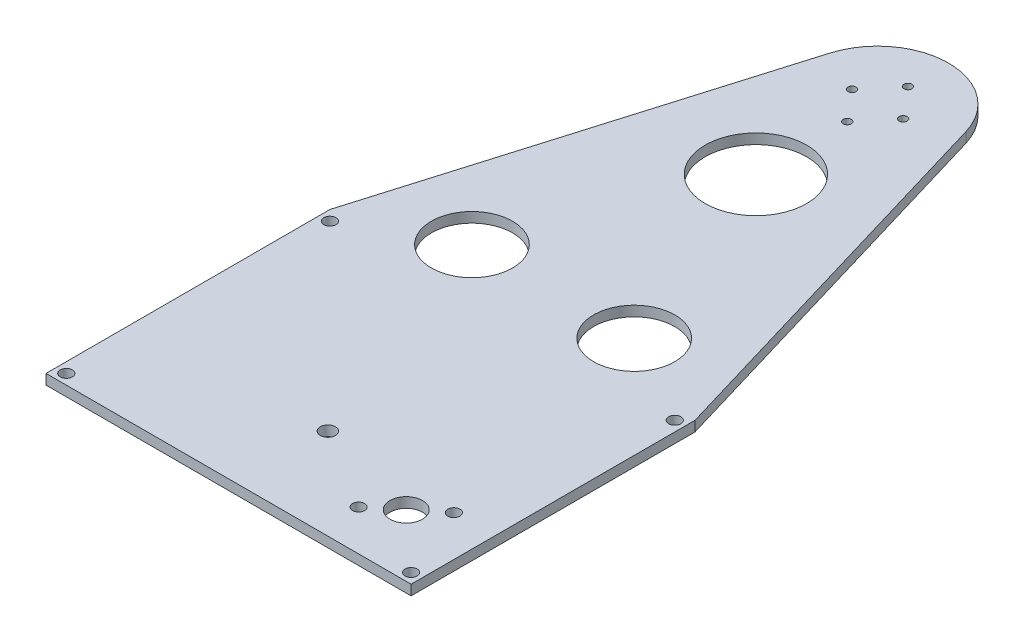
from build123d import *

# Parameters (mm, degrees)
SKETCH3_W                = 114.3
SKETCH3_H                = 88.9
SKETCH3_W_2              = 101.6
SKETCH3_H_2              = 76.2
BOSS_EXTRUDE1_DEPTH      = 12.7
BOSS_EXTRUDE1_DEPTH_BACK = 12.7
SKETCH4_W                = 114.3
SKETCH4_H                = 88.9
BOSS_EXTRUDE2_DEPTH      = 3.175
BOSS_EXTRUDE3_DEPTH      = 3.175
SKETCH7_W                = 44.45
SKETCH7_H                = 25.4
BOSS_EXTRUDE4_DEPTH      = 6.35
SKETCH6_R                = 9.9695
CUT_EXTRUDE1_DEPTH       = 115.3
SKETCH13_W               = 29.21
SKETCH13_H               = 25.4
BOSS_EXTRUDE5_DEPTH      = 4.064
SKETCH14_W               = 6.35
SKETCH14_H               = 2.54
CUT_EXTRUDE2_DEPTH       = 31.75
SKETCH18_W               = 10.16
SKETCH18_H               = 5.08
CUT_EXTRUDE3_DEPTH       = 6.35
SKETCH19_R               = 0.635
CUT_EXTRUDE4_DEPTH       = 25.4
SKETCH20_R               = 1.905
CUT_EXTRUDE7_DEPTH       = 3.175
SKETCH23_R               = 5.08
SKETCH23_R_2             = 1.905
SKETCH23_R_3             = 2.38125
CUT_EXTRUDE8_DEPTH       = 3.175
SKETCH24_R               = 1.25
CUT_EXTRUDE9_DEPTH       = 3.175
BOSS_EXTRUDE7_DEPTH      = 114.3
BOSS_EXTRUDE8_DEPTH      = 28.575
SKETCH25_R               = 15.875
SKETCH25_R_2             = 12.7
CUT_EXTRUDE10_DEPTH      = 32.75
FILLET1_R                = 9.525
FILLET2_R                = 5.08
FILLET3_R                = 9.525


with BuildPart() as part:
    # Sketch3 → Boss-Extrude1 (new body, two sides)
    with BuildSketch(Plane(origin=(0, 0, 0), x_dir=(1, 0, 0), z_dir=(0, 1, 0))) as boss_extrude1_sk:
        with Locations((0, -158.75)):
            Rectangle(SKETCH3_W, SKETCH3_H)
        with Locations((0, -158.75)):
            Rectangle(SKETCH3_W_2, SKETCH3_H_2, mode=Mode.SUBTRACT)
    extrude(amount=BOSS_EXTRUDE1_DEPTH)
    extrude(boss_extrude1_sk.sketch, amount=-BOSS_EXTRUDE1_DEPTH_BACK)

    # Sketch4 → Boss-Extrude2 (add)
    with BuildSketch(Plane.XZ.offset(12.7)):
        with Locations((0, 158.75)):
            Rectangle(SKETCH4_W, SKETCH4_H)
    extrude(amount=BOSS_EXTRUDE2_DEPTH)

    # Sketch7 → Boss-Extrude4 (add)
    with BuildSketch(Plane(origin=(0, -12.7, 0), x_dir=(1, 0, 0), z_dir=(0, 1, 0))):
        with Locations((-28.575, -133.35)):
            Rectangle(SKETCH7_W, SKETCH7_H)
        with Locations((28.575, -133.35)):
            Rectangle(SKETCH7_W, SKETCH7_H)
    extrude(amount=BOSS_EXTRUDE4_DEPTH)

    # Sketch6 → Cut-Extrude1 (cut, through all)
    with BuildSketch(Plane.ZY.offset(57.15)):
        with Locations((133.35, 0)):
            Circle(SKETCH6_R)
    extrude(amount=-CUT_EXTRUDE1_DEPTH, mode=Mode.SUBTRACT)

    # Sketch13 → Boss-Extrude5 (add)
    with BuildSketch(Plane(origin=(0, -12.7, 0), x_dir=(1, 0, 0), z_dir=(0, 1, 0))):
        with Locations((-20.955, -133.35)):
            Rectangle(SKETCH13_W, SKETCH13_H)
        with Locations((20.955, -133.35)):
            Rectangle(SKETCH13_W, SKETCH13_H)
    extrude(amount=BOSS_EXTRUDE5_DEPTH)

    # Sketch14 → Cut-Extrude2 (cut)
    with BuildSketch(Plane.XY.offset(146.05)):
        with Locations((-27.305, -10.414)):
            Rectangle(SKETCH14_W, SKETCH14_H)
        with Locations((-27.305, -3.81)):
            Rectangle(SKETCH14_W, SKETCH14_H)
        with Locations((27.305, -10.414)):
            Rectangle(SKETCH14_W, SKETCH14_H)
        with Locations((27.305, -3.81)):
            Rectangle(SKETCH14_W, SKETCH14_H)
    extrude(amount=-CUT_EXTRUDE2_DEPTH, mode=Mode.SUBTRACT)

    # Sketch18 → Cut-Extrude3 (cut)
    with BuildSketch(Plane.XY.offset(120.65)):
        with Locations((-43.18, 10.16)):
            Rectangle(SKETCH18_W, SKETCH18_H)
    extrude(amount=-CUT_EXTRUDE3_DEPTH, mode=Mode.SUBTRACT)

    # Sketch19 → Cut-Extrude4 (cut)
    with BuildSketch(Plane(origin=(0, 12.7, 0), x_dir=(1, 0, 0), z_dir=(0, 1, 0))):
        with Locations((-53.975, -117.475)):
            Circle(SKETCH19_R)
        with Locations((53.975, -117.475)):
            Circle(SKETCH19_R)
        with Locations((-53.975, -200.025)):
            Circle(SKETCH19_R)
        with Locations((53.975, -200.025)):
            Circle(SKETCH19_R)
    extrude(amount=-CUT_EXTRUDE4_DEPTH, mode=Mode.SUBTRACT)

    # Sketch26 → Boss-Extrude7 (add)
    with BuildSketch(Plane(origin=(57.15, 0, 0), x_dir=(0, 0, -1), z_dir=(1, 0, 0))):
        Polygon((-203.2, 12.7), (-203.454, 12.7), (-203.454, 15.875), (-204.724, 15.875), (-213.23138686, -15.875), (-203.2, -15.875), align=None)
    extrude(amount=-BOSS_EXTRUDE7_DEPTH)

    # Sketch27 → Boss-Extrude8 (add)
    with BuildSketch(Plane.XZ.offset(15.875)):
        Polygon((57.15, 171.45), (95.25, 171.45), (95.25, 128.27), (100.33, 128.27), (100.33, 176.536200973), (57.15, 184.15), align=None)
        Polygon((-100.33, 176.536200973), (-57.15, 184.15), (-57.15, 171.45), (-95.25, 171.45), (-95.25, 128.27), (-100.33, 128.27), align=None)
    extrude(amount=-BOSS_EXTRUDE8_DEPTH)

    # Fillet1
    fillet1_edges = [part.edges().sort_by_distance(p)[0] for p in [
        (57.15, -1.5875, 184.15),
        (100.33, -1.5875, 176.536200973),
        (95.25, -1.5875, 171.45),
        (-100.33, -1.5875, 176.536200973),
        (-57.15, -1.5875, 184.15),
        (-95.25, -1.5875, 171.45),
    ]]
    fillet(fillet1_edges, radius=FILLET1_R)

    # Fillet2
    fillet2_edges = [part.edges().sort_by_distance(p)[0] for p in [
        (57.15, -1.5875, 171.45),
        (-57.15, -1.5875, 171.45),
    ]]
    fillet(fillet2_edges, radius=FILLET2_R)

    # Fillet3
    fillet3_edges = [part.edges().sort_by_distance(p)[0] for p in [
        (97.79, -15.875, 128.27),
        (97.79, 12.7, 128.27),
        (-97.79, -15.875, 128.27),
        (-97.79, 12.7, 128.27),
    ]]
    fillet(fillet3_edges, radius=FILLET3_R)


with BuildPart() as body_2:
    # Sketch5 → Boss-Extrude3 (new body)
    with BuildSketch(Plane(origin=(0, 12.7, 0), x_dir=(1, 0, 0), z_dir=(0, 1, 0))):
        with BuildLine():
            Line((-21.304313257, 6.330628851), (-57.15, -114.3))
            Line((-57.15, -114.3), (-57.15, -203.2))
            Line((-57.15, -203.2), (57.15, -203.2))
            Line((57.15, -203.2), (57.15, -114.3))
            Line((57.15, -114.3), (21.304313257, 6.330628851))
            ThreePointArc((21.304313257, 6.330628851), (0, 22.225), (-21.304313257, 6.330628851))
        make_face()
    extrude(amount=BOSS_EXTRUDE3_DEPTH)

    # Sketch20 → Cut-Extrude7 (cut)
    with BuildSketch(Plane(origin=(0, 15.875, 0), x_dir=(1, 0, 0), z_dir=(0, 1, 0))):
        with Locations((-53.975, -117.475)):
            Circle(SKETCH20_R)
        with Locations((-53.975, -200.025)):
            Circle(SKETCH20_R)
        with Locations((53.975, -200.025)):
            Circle(SKETCH20_R)
        with Locations((53.975, -117.475)):
            Circle(SKETCH20_R)
    extrude(amount=-CUT_EXTRUDE7_DEPTH, mode=Mode.SUBTRACT)

    # Sketch23 → Cut-Extrude8 (cut)
    with BuildSketch(Plane(origin=(0, 15.875, 0), x_dir=(1, 0, 0), z_dir=(0, 1, 0))):
        with Locations((36.232509154, -183.804266718)):
            Circle(SKETCH23_R)
        with Locations((44.45, -177.108533435)):
            Circle(SKETCH23_R_2)
        with Locations((28.015018307, -190.5)):
            Circle(SKETCH23_R_2)
        with Locations((2.615018307, -174.727283435)):
            Circle(SKETCH23_R_3)
    extrude(amount=-CUT_EXTRUDE8_DEPTH, mode=Mode.SUBTRACT)

    # Sketch24 → Cut-Extrude9 (cut)
    with BuildSketch(Plane(origin=(0, 15.875, 0), x_dir=(1, 0, 0), z_dir=(0, 1, 0))):
        with Locations((0, 9.5)):
            Circle(SKETCH24_R)
        with Locations((0, -9.5)):
            Circle(SKETCH24_R)
        with Locations((-8, 0)):
            Circle(SKETCH24_R)
        with Locations((8, 0)):
            Circle(SKETCH24_R)
    extrude(amount=-CUT_EXTRUDE9_DEPTH, mode=Mode.SUBTRACT)

    # Sketch25 → Cut-Extrude10 (cut, through all)
    with BuildSketch(Plane(origin=(0, 15.875, 0), x_dir=(1, 0, 0), z_dir=(0, 1, 0))):
        with Locations((0, -38.1)):
            Circle(SKETCH25_R)
        with Locations((-25.4, -101.6)):
            Circle(SKETCH25_R_2)
        with Locations((25.4, -101.6)):
            Circle(SKETCH25_R_2)
    extrude(amount=-CUT_EXTRUDE10_DEPTH, mode=Mode.SUBTRACT)


solid = body_2.part
